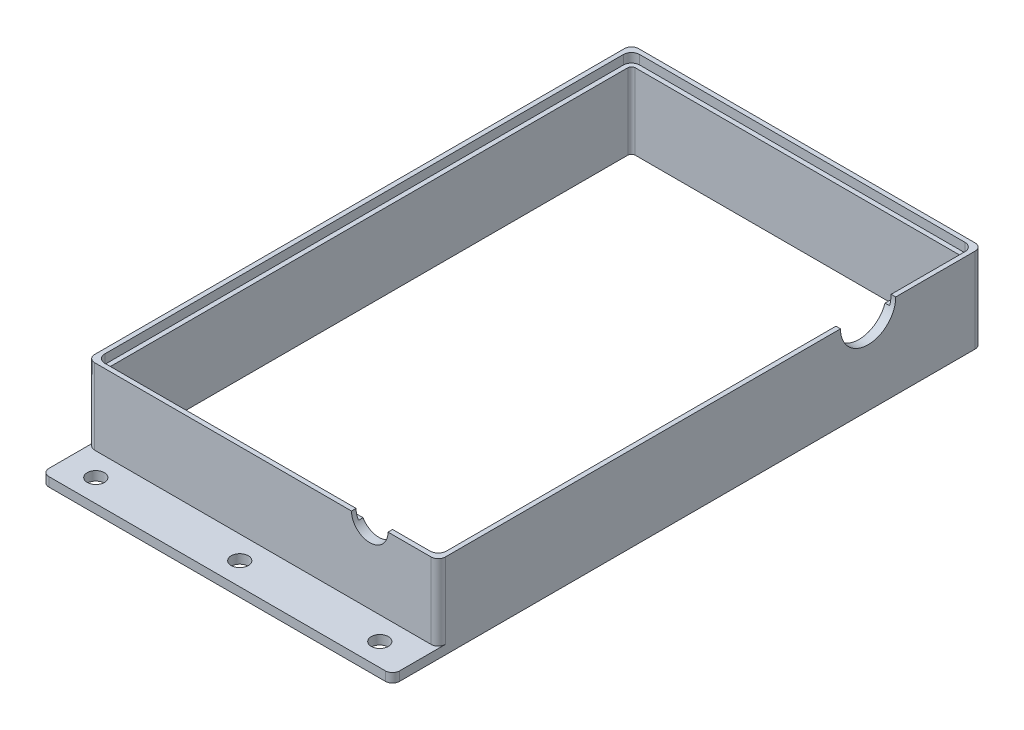
from build123d import *

# Parameters (mm, degrees)
SKETCH1_W                          = 97.571055574
SKETCH1_H                          = 151.345533826
SKETCH1_W_2                        = 92.491055574
SKETCH1_H_2                        = 146.265533826
BOSS_EXTRUDE1_DEPTH                = 23.619000006
SKETCH2_W                          = 97.571055574
SKETCH2_H                          = 12.724538291
BOSS_EXTRUDE2_DEPTH                = 2.54
FILLET1_R                          = 2
FILLET2_R                          = 1
F_3_16_0_1875_DIAMETER_HOLE1_D     = 4.7625
F_3_16_0_1875_DIAMETER_HOLE1_DEPTH = 20.066
F_3_16_0_1875_DIAMETER_HOLE1_TIP   = 1.430799349
CUT_EXTRUDE1_DEPTH                 = 2.54
CUT_EXTRUDE2_REACH                 = 99.571
SKETCH8_R                          = 7.6835
CUT_EXTRUDE3_REACH                 = 153.346
SKETCH9_R                          = 5.08


with BuildPart() as part:
    # Sketch1 → Boss-Extrude1 (new body)
    with BuildSketch(Plane(origin=(0, 0, 0), x_dir=(1, 0, 0), z_dir=(0, 1, 0))):
        Rectangle(SKETCH1_W, SKETCH1_H)
        Rectangle(SKETCH1_W_2, SKETCH1_H_2, mode=Mode.SUBTRACT)
    extrude(amount=BOSS_EXTRUDE1_DEPTH)

    # Sketch2 → Boss-Extrude2 (add)
    with BuildSketch(Plane.XZ):
        with Locations((0, 82.035036058)):
            Rectangle(SKETCH2_W, SKETCH2_H)
    extrude(amount=-BOSS_EXTRUDE2_DEPTH)

    # Fillet1
    fillet1_edges = [part.edges().sort_by_distance(p)[0] for p in [
        (-48.785527787, 1.27, 88.397305204),
        (48.785527787, 1.27, 88.397305204),
        (48.785527787, 13.079500003, 75.672766913),
        (-48.785527787, 13.079500003, 75.672766913),
        (-48.785527787, 11.809500003, -75.672766913),
        (48.785527787, 11.809500003, -75.672766913),
    ]]
    fillet(fillet1_edges, radius=FILLET1_R)

    # Fillet2
    fillet2_edges = [part.edges().sort_by_distance(p)[0] for p in [
        (46.245527787, 11.809500003, 73.132766913),
        (46.245527787, 11.809500003, -73.132766913),
        (-46.245527787, 11.809500003, -73.132766913),
        (-46.245527787, 11.809500003, 73.132766913),
    ]]
    fillet(fillet2_edges, radius=FILLET2_R)

    # 3/16 (0.1875) Diameter Hole1
    with Locations(Plane(origin=(0, 2.54, 0), x_dir=(1, 0, 0), z_dir=(0, 1, 0))):
        with Locations((-40.04587174, -82.10120048), (38.957668704, -82.10120048), (0, -82.10120048)):
            Hole(F_3_16_0_1875_DIAMETER_HOLE1_D / 2, depth=F_3_16_0_1875_DIAMETER_HOLE1_DEPTH)
            with Locations((0, 0, -(F_3_16_0_1875_DIAMETER_HOLE1_DEPTH + F_3_16_0_1875_DIAMETER_HOLE1_TIP / 2))):  # 118° drill point
                Cone(0, F_3_16_0_1875_DIAMETER_HOLE1_D / 2, F_3_16_0_1875_DIAMETER_HOLE1_TIP, mode=Mode.SUBTRACT)

    # Sketch5 → Cut-Extrude1 (cut)
    with BuildSketch(Plane(origin=(0, 23.619000006, 0), x_dir=(1, 0, 0), z_dir=(0, 1, 0))):
        with BuildLine():
            Line((-45.245527787, -74.402766913), (45.245527787, -74.402766913))
            ThreePointArc((45.245527787, -74.402766913), (46.85066018, -73.737899306), (47.515527787, -72.132766913))
            Line((47.515527787, -72.132766913), (47.515527787, 72.132766913))
            ThreePointArc((47.515527787, 72.132766913), (46.85066018, 73.737899306), (45.245527787, 74.402766913))
            Line((45.245527787, 74.402766913), (-45.245527787, 74.402766913))
            ThreePointArc((-45.245527787, 74.402766913), (-46.85066018, 73.737899306), (-47.515527787, 72.132766913))
            Line((-47.515527787, 72.132766913), (-47.515527787, -72.132766913))
            ThreePointArc((-47.515527787, -72.132766913), (-46.85066018, -73.737899306), (-45.245527787, -74.402766913))
        make_face()
        with BuildLine():
            Line((-46.245527787, 72.132766913), (-46.245527787, -72.132766913))
            ThreePointArc((-46.245527787, -72.132766913), (-45.952634568, -72.839873694), (-45.245527787, -73.132766913))
            Line((-45.245527787, -73.132766913), (45.245527787, -73.132766913))
            ThreePointArc((45.245527787, -73.132766913), (45.952634568, -72.839873694), (46.245527787, -72.132766913))
            Line((46.245527787, -72.132766913), (46.245527787, 72.132766913))
            ThreePointArc((46.245527787, 72.132766913), (45.952634568, 72.839873694), (45.245527787, 73.132766913))
            Line((45.245527787, 73.132766913), (-45.245527787, 73.132766913))
            ThreePointArc((-45.245527787, 73.132766913), (-45.952634568, 72.839873694), (-46.245527787, 72.132766913))
        make_face(mode=Mode.SUBTRACT)
    extrude(amount=-CUT_EXTRUDE1_DEPTH, mode=Mode.SUBTRACT)

    # Sketch8 → Cut-Extrude2 (cut, up to next)
    with BuildSketch(Plane(origin=(48.785527787, 0, 0), x_dir=(0, 0, -1), z_dir=(1, 0, 0)), mode=Mode.PRIVATE) as cut_extrude2_sk1:
        with Locations((43.922766913, 23.619000006)):
            Circle(SKETCH8_R)
    cut_extrude2_tool1 = extrude(cut_extrude2_sk1.sketch, amount=-CUT_EXTRUDE2_REACH, mode=Mode.PRIVATE) & part.part
    add(cut_extrude2_tool1.solids().sort_by_distance((48.785528, 23.619, -43.922767))[0], mode=Mode.SUBTRACT)

    # Sketch9 → Cut-Extrude3 (cut, up to next)
    with BuildSketch(Plane.XY.offset(75.672766913), mode=Mode.PRIVATE) as cut_extrude3_sk1:
        with Locations((29.735527787, 23.619000006)):
            Circle(SKETCH9_R)
    cut_extrude3_tool1 = extrude(cut_extrude3_sk1.sketch, amount=-CUT_EXTRUDE3_REACH, mode=Mode.PRIVATE) & part.part
    add(cut_extrude3_tool1.solids().sort_by_distance((29.735528, 23.619, 75.672767))[0], mode=Mode.SUBTRACT)


solid = part.part
